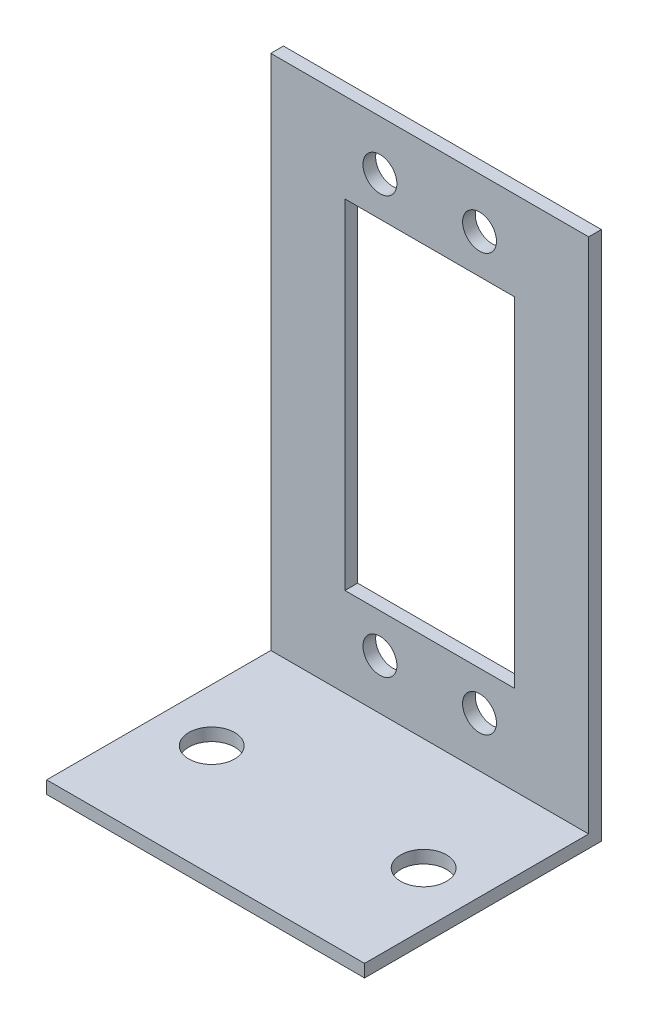
from build123d import *

# Parameters (mm, degrees)
BOSS_EXTRUDE1_DEPTH  = 19.05
M5_CLEARANCE_HOLE1_D = 5.5
CUT_EXTRUDE1_REACH   = 3.519
SKETCH5_W            = 20.32
SKETCH5_H            = 40.64
CUT_EXTRUDE2_REACH   = 3.519
SKETCH6_R            = 2.032


with BuildPart() as part:
    # Sketch1 → Boss-Extrude1 (new body, symmetric)
    with BuildSketch(Plane(origin=(0, 0, 0), x_dir=(0, 0, -1), z_dir=(1, 0, 0))):
        Polygon((0, 0), (28.380612245, 0), (28.380612245, 63.5), (26.861692245, 63.5), (26.861692245, 1.51892), (0, 1.51892), align=None)
    extrude(amount=BOSS_EXTRUDE1_DEPTH, both=True)

    # M5 Clearance Hole1 (through all)
    with Locations(Plane(origin=(0, 1.51892, 0), x_dir=(1, 0, 0), z_dir=(0, 1, 0))):
        with Locations((-12.7, 13.430846122), (12.7, 13.430846122)):
            Hole(M5_CLEARANCE_HOLE1_D / 2)

    # Sketch5 → Cut-Extrude1 (cut, up to next)
    with BuildSketch(Plane.XY.offset(-26.861692245), mode=Mode.PRIVATE) as cut_extrude1_sk1:
        with Locations((0, 32.50946)):
            Rectangle(SKETCH5_W, SKETCH5_H)
    cut_extrude1_tool1 = extrude(cut_extrude1_sk1.sketch, amount=-CUT_EXTRUDE1_REACH, mode=Mode.PRIVATE) & part.part
    add(cut_extrude1_tool1.solids().sort_by_distance((0, 32.50946, -26.861692))[0], mode=Mode.SUBTRACT)

    # Sketch6 → Cut-Extrude2 (cut, up to next)
    with BuildSketch(Plane.XY.offset(-26.861692245), mode=Mode.PRIVATE) as cut_extrude2_sk1:
        with Locations((-5.969, 57.50946)):
            Circle(SKETCH6_R)
    cut_extrude2_tool1 = extrude(cut_extrude2_sk1.sketch, amount=-CUT_EXTRUDE2_REACH, mode=Mode.PRIVATE) & part.part
    add(cut_extrude2_tool1.solids().sort_by_distance((-5.969, 57.50946, -26.861692))[0], mode=Mode.SUBTRACT)
    # Sketch6 → Cut-Extrude2 (cut, up to next)
    with BuildSketch(Plane.XY.offset(-26.861692245), mode=Mode.PRIVATE) as cut_extrude2_sk2:
        with Locations((5.969, 57.50946)):
            Circle(SKETCH6_R)
    cut_extrude2_tool2 = extrude(cut_extrude2_sk2.sketch, amount=-CUT_EXTRUDE2_REACH, mode=Mode.PRIVATE) & part.part
    add(cut_extrude2_tool2.solids().sort_by_distance((5.969, 57.50946, -26.861692))[0], mode=Mode.SUBTRACT)
    # Sketch6 → Cut-Extrude2 (cut, up to next)
    with BuildSketch(Plane.XY.offset(-26.861692245), mode=Mode.PRIVATE) as cut_extrude2_sk3:
        with Locations((-5.969, 7.50946)):
            Circle(SKETCH6_R)
    cut_extrude2_tool3 = extrude(cut_extrude2_sk3.sketch, amount=-CUT_EXTRUDE2_REACH, mode=Mode.PRIVATE) & part.part
    add(cut_extrude2_tool3.solids().sort_by_distance((-5.969, 7.50946, -26.861692))[0], mode=Mode.SUBTRACT)
    # Sketch6 → Cut-Extrude2 (cut, up to next)
    with BuildSketch(Plane.XY.offset(-26.861692245), mode=Mode.PRIVATE) as cut_extrude2_sk4:
        with Locations((5.969, 7.50946)):
            Circle(SKETCH6_R)
    cut_extrude2_tool4 = extrude(cut_extrude2_sk4.sketch, amount=-CUT_EXTRUDE2_REACH, mode=Mode.PRIVATE) & part.part
    add(cut_extrude2_tool4.solids().sort_by_distance((5.969, 7.50946, -26.861692))[0], mode=Mode.SUBTRACT)


solid = part.part
